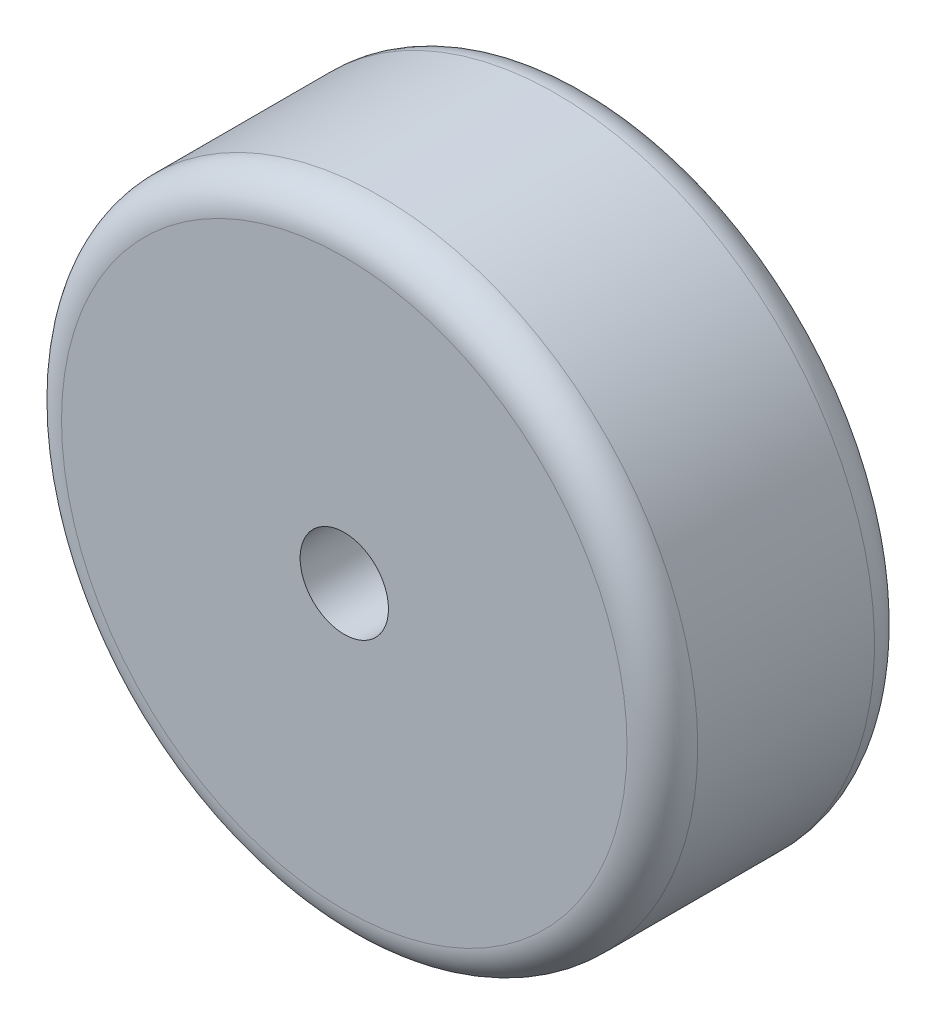
from build123d import *

# Parameters (mm, degrees)
SKETCH1_R           = 18
BOSS_EXTRUDE1_DEPTH = 7
FILLET2_R           = 2
CUT_EXTRUDE1_REACH  = 16
SKETCH2_R           = 2.5


with BuildPart() as part:
    # Sketch1 → Boss-Extrude1 (new body)
    with BuildSketch(Plane.XY):
        Circle(SKETCH1_R)
    boss_extrude1 = extrude(amount=BOSS_EXTRUDE1_DEPTH)

    # Mirror1: Boss-Extrude1 across plane
    add(boss_extrude1.mirror(Plane.XY))

    # Fillet2
    fillet2_edges = [part.edges().sort_by_distance(p)[0] for p in [
        (-18, 0, 7),
        (-18, 0, -7),
    ]]
    fillet(fillet2_edges, radius=FILLET2_R)

    # Sketch2 → Cut-Extrude1 (cut, up to next)
    with BuildSketch(Plane.XY.offset(7), mode=Mode.PRIVATE) as cut_extrude1_sk1:
        Circle(SKETCH2_R)
    cut_extrude1_tool1 = extrude(cut_extrude1_sk1.sketch, amount=-CUT_EXTRUDE1_REACH, mode=Mode.PRIVATE) & part.part
    add(cut_extrude1_tool1.solids().sort_by_distance((0, 0, 7))[0], mode=Mode.SUBTRACT)


solid = part.part
